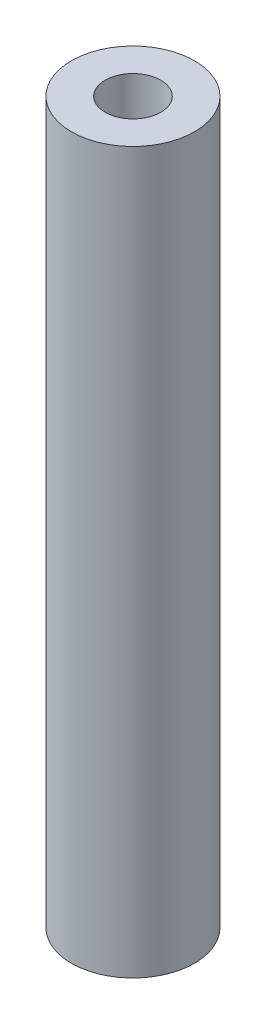
from build123d import *

# Parameters (mm, degrees)
SKETCH1_R           = 4.7625
SKETCH1_R_2         = 2.15265
BOSS_EXTRUDE1_DEPTH = 55.7276


with BuildPart() as part:
    # Sketch1 → Boss-Extrude1 (new body)
    with BuildSketch(Plane(origin=(0, 0, 0), x_dir=(1, 0, 0), z_dir=(0, 1, 0))):
        Circle(SKETCH1_R)
        Circle(SKETCH1_R_2, mode=Mode.SUBTRACT)
    extrude(amount=BOSS_EXTRUDE1_DEPTH)


solid = part.part
